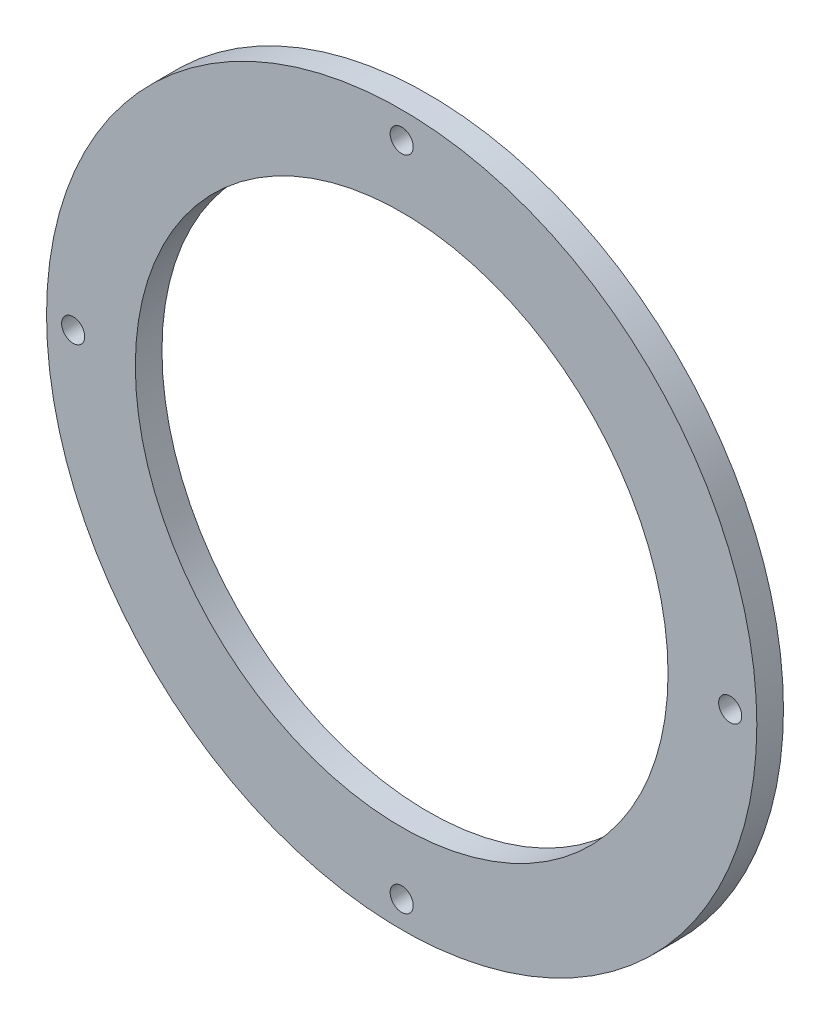
from build123d import *

# Parameters (mm, degrees)
ESQUISSE1_R                  = 40
BOSS_EXTRU_1_DEPTH           = 3
D_GAGEMENT_M21_D             = 2.6
R_P_TITION_CIRCULAIRE1_COUNT = 4
ESQUISSE4_R                  = 30
ENL_V_MAT_EXTRU_1_DEPTH      = 10


with BuildPart() as part:
    # Esquisse1 → Boss.-Extru.1 (new body)
    with BuildSketch(Plane.XY):
        Circle(ESQUISSE1_R)
    extrude(amount=BOSS_EXTRU_1_DEPTH)

    # Dégagement M21 (through all)
    with Locations(Plane(origin=(0, 0, 0), x_dir=(-1, 0, 0), z_dir=(0, 0, -1))):
        with Locations((0, 37)):
            d_gagement_m21 = Hole(D_GAGEMENT_M21_D / 2)

    # Répétition circulaire1: Dégagement M21 ×4 about axis
    r_p_tition_circulaire1_axis = Axis((0, 0, 0), (0, 0, 1))
    for i in range(1, R_P_TITION_CIRCULAIRE1_COUNT):
        add(d_gagement_m21.rotate(r_p_tition_circulaire1_axis, i * 360 / R_P_TITION_CIRCULAIRE1_COUNT), mode=Mode.SUBTRACT)

    # Esquisse4 → Enlèv. mat.-Extru.1 (cut)
    with BuildSketch(Plane(origin=(0, 0, 0), x_dir=(-1, 0, 0), z_dir=(0, 0, -1))):
        Circle(ESQUISSE4_R)
    extrude(amount=-ENL_V_MAT_EXTRU_1_DEPTH, mode=Mode.SUBTRACT)


solid = part.part
